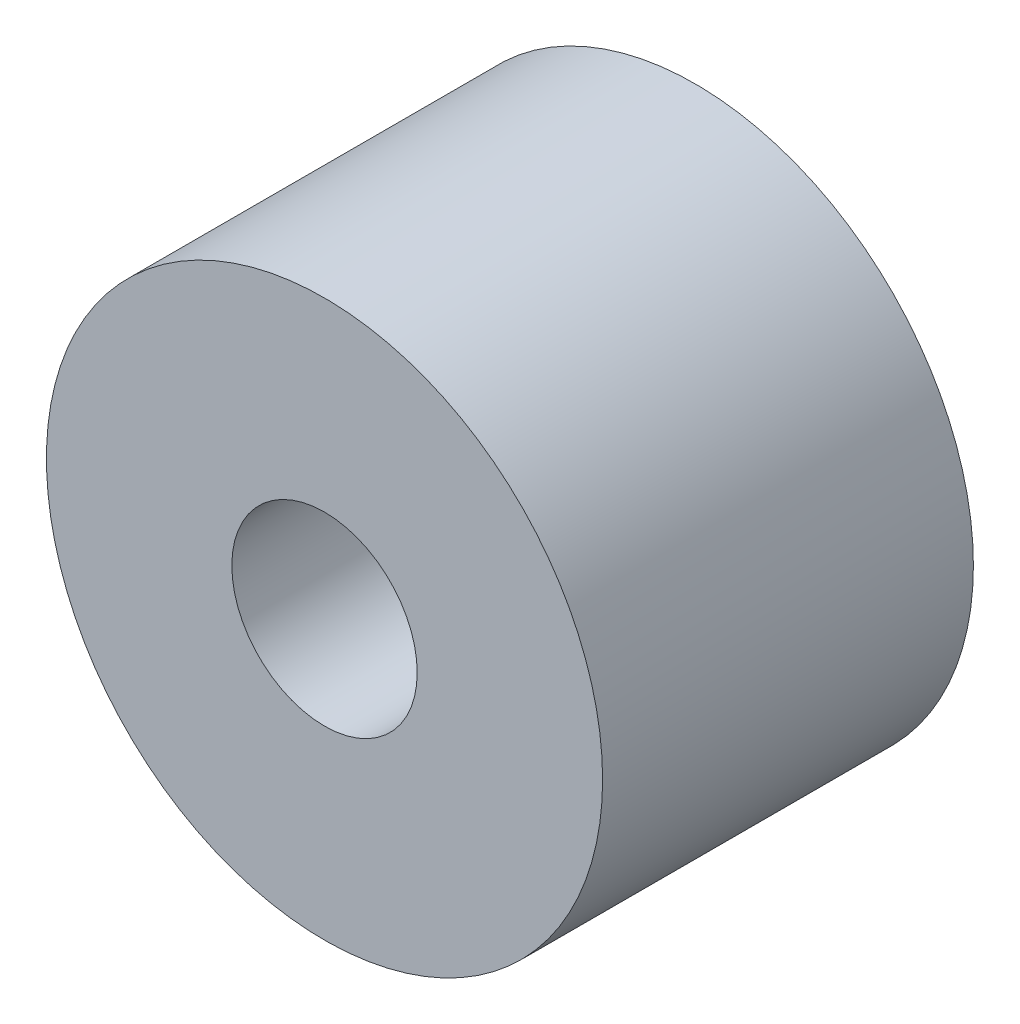
from build123d import *

# Parameters (mm, degrees)
SKETCH1_R           = 6
SKETCH1_R_2         = 2
BOSS_EXTRUDE1_DEPTH = 8


with BuildPart() as part:
    # Sketch1 → Boss-Extrude1 (new body)
    with BuildSketch(Plane.XY):
        Circle(SKETCH1_R)
        Circle(SKETCH1_R_2, mode=Mode.SUBTRACT)
    extrude(amount=BOSS_EXTRUDE1_DEPTH)


solid = part.part
